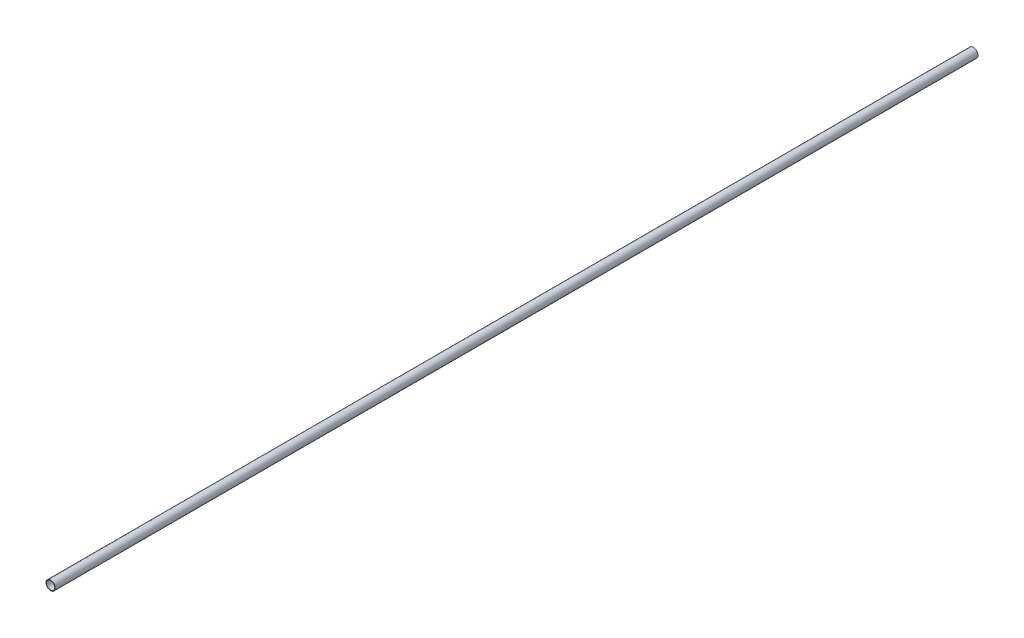
from build123d import *

# Parameters (mm, degrees)
SKETCH_1_R      = 10
SKETCH_1_R_2    = 9
EXTRUDE_1_DEPTH = 1000


with BuildPart() as part:
    # Эскиз1 → Бобышка-Вытянуть1 (new body, symmetric)
    with BuildSketch(Plane.XY):
        Circle(SKETCH_1_R)
        Circle(SKETCH_1_R_2, mode=Mode.SUBTRACT)
    extrude(amount=EXTRUDE_1_DEPTH, both=True)


solid = part.part
